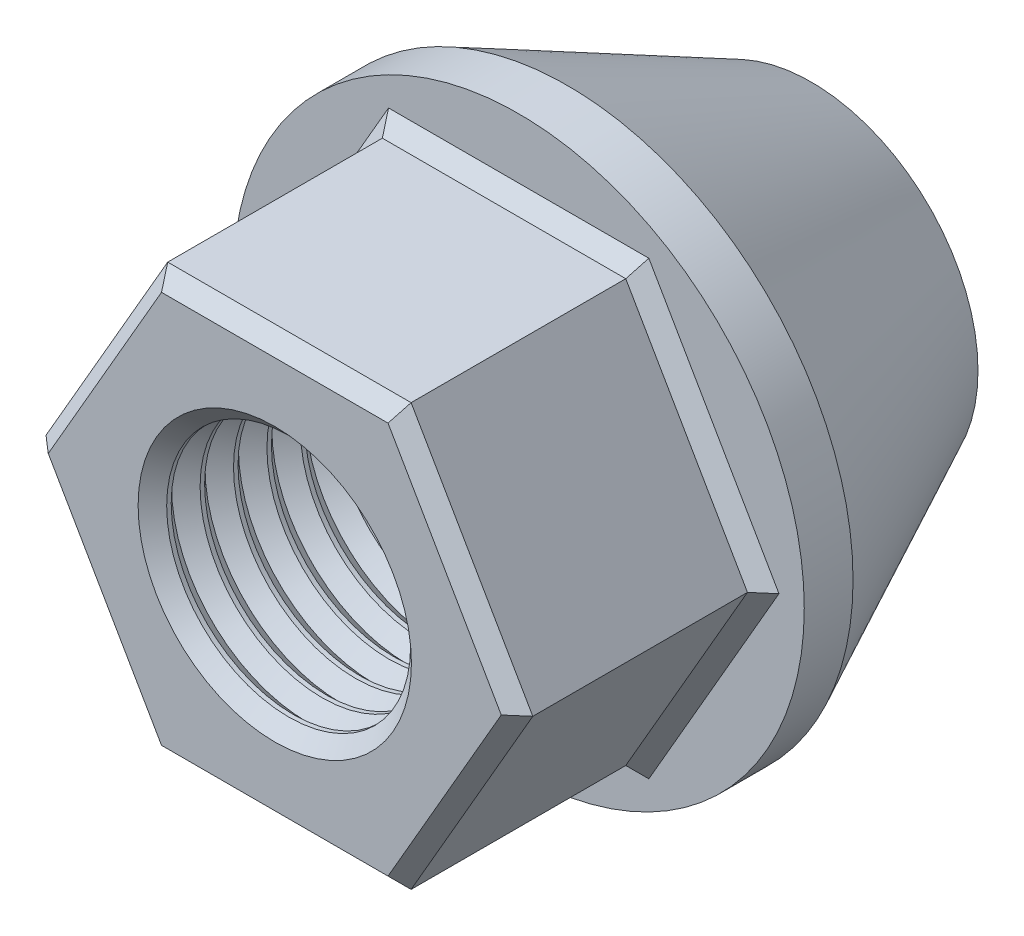
from build123d import *

# Parameters (mm, degrees)
EXTRUDE1_DEPTH     = 12.7
SKETCH3_R          = 14.869502809
EXTRUDE2_DEPTH     = 2.54
CHAMFER1_SIZE      = 0.762
CHAMFER2_SIZE      = 0.762
SKETCH5_R          = 14.869502809
EXTRUDE3_DEPTH     = 12.7
EXTRUDE3_TAPER     = 26
SKETCH4_R          = 6.35
CUT_EXTRUDE1_DEPTH = 28.9400001
LPATTERN2_COUNT    = 17
LPATTERN2_PITCH    = 1.74


with BuildPart() as part:
    # Sketch2 → Extrude1 (new body)
    with BuildSketch(Plane.XY):
        Polygon((12.673375262, 0), (6.336687631, 10.975464929), (-6.336687631, 10.975464929), (-12.673375262, 0), (-6.336687631, -10.975464929), (6.336687631, -10.975464929), align=None)
    extrude(amount=EXTRUDE1_DEPTH)

    # Sketch3 → Extrude2 (add)
    with BuildSketch(Plane(origin=(0, 0, 0), x_dir=(-1, 0, 0), z_dir=(0, 0, -1))):
        Circle(SKETCH3_R)
    extrude(amount=EXTRUDE2_DEPTH)

    # Chamfer1
    chamfer1_edges = [part.edges().sort_by_distance(p)[0] for p in [
        (0, -10.975464929, 0),
        (-9.505031447, -5.487732464, 0),
        (-9.505031447, 5.487732464, 0),
        (0, 10.975464929, 0),
        (9.505031447, 5.487732464, 0),
        (9.505031447, -5.487732464, 0),
    ]]
    chamfer(chamfer1_edges, length=CHAMFER1_SIZE)

    # Chamfer2
    chamfer2_edges = [part.edges().sort_by_distance(p)[0] for p in [
        (0, 10.975464929, 12.7),
        (-9.505031447, 5.487732464, 12.7),
        (-9.505031447, -5.487732464, 12.7),
        (0, -10.975464929, 12.7),
        (9.505031447, -5.487732464, 12.7),
        (9.505031447, 5.487732464, 12.7),
    ]]
    chamfer(chamfer2_edges, length=CHAMFER2_SIZE)

    # Sketch5 → Extrude3 (add)
    with BuildSketch(Plane(origin=(0, 0, -2.54), x_dir=(-1, 0, 0), z_dir=(0, 0, -1))):
        Circle(SKETCH5_R)
    extrude(amount=EXTRUDE3_DEPTH, taper=EXTRUDE3_TAPER)

    # Sketch4 → Cut-Extrude1 (cut, through all)
    with BuildSketch(Plane.XY.offset(12.7)):
        Circle(SKETCH4_R)
    extrude(amount=-CUT_EXTRUDE1_DEPTH, mode=Mode.SUBTRACT)

    # Sketch7 → Cut-Revolve1 (revolve, cut)
    with BuildSketch(Plane(origin=(0, 0, 0), x_dir=(1, 0, 0), z_dir=(0, 1, 0))):
        Polygon((6.340392923, -11.96936439), (7.115488803, -12.7), (6.340392923, -13.49336439), (5.591488803, -12.7), align=None)
    cut_revolve1 = revolve(axis=Axis((0, 0, -15.24), (0, 0, 1)), mode=Mode.SUBTRACT)

    # LPattern2: Cut-Revolve1 ×17
    with Locations(*[(0, 0, -i * LPATTERN2_PITCH) for i in range(1, LPATTERN2_COUNT)]):
        add(cut_revolve1, mode=Mode.SUBTRACT)


solid = part.part
